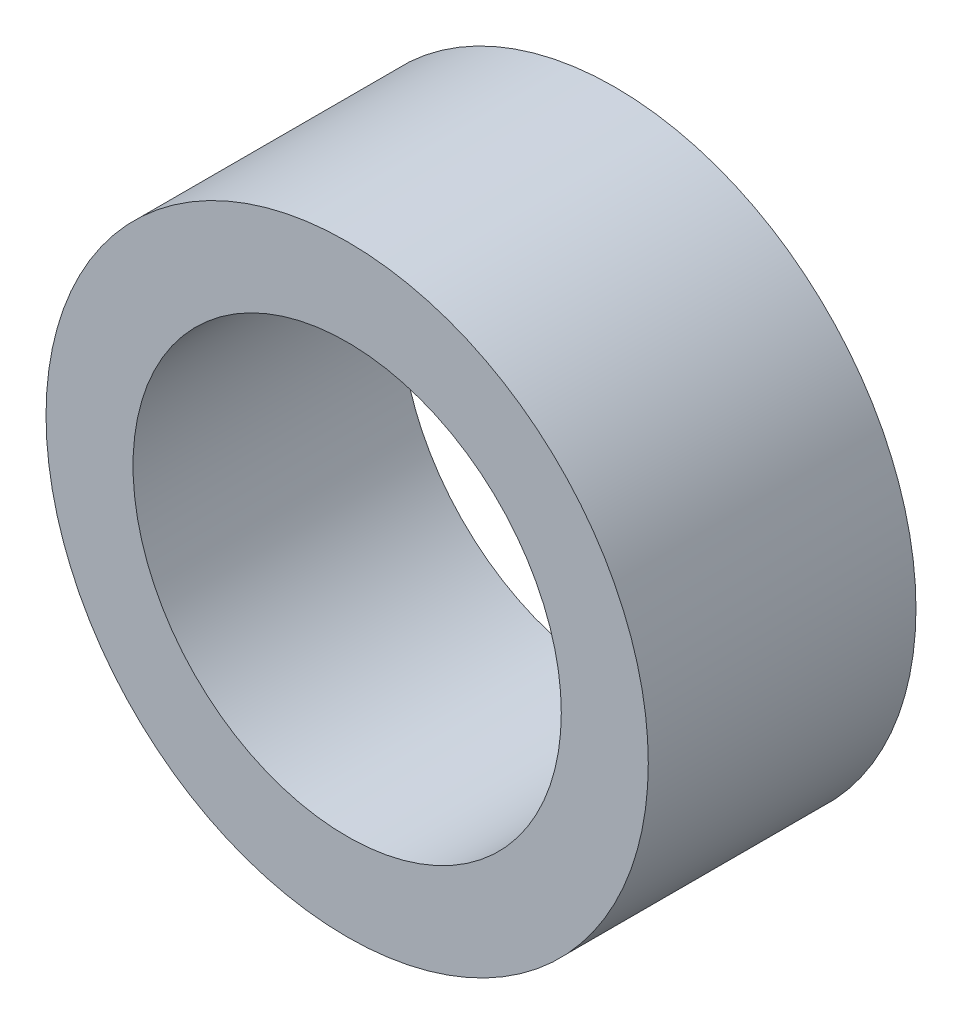
from build123d import *

# Parameters (mm, degrees)
SKETCH1_R      = 2.25
SKETCH1_R_2    = 1.6
EXTRUDE1_DEPTH = 1


with BuildPart() as part:
    # Sketch1 → Extrude1 (new body, symmetric)
    with BuildSketch(Plane.XY):
        Circle(SKETCH1_R)
        Circle(SKETCH1_R_2, mode=Mode.SUBTRACT)
    extrude(amount=EXTRUDE1_DEPTH, both=True)


solid = part.part
